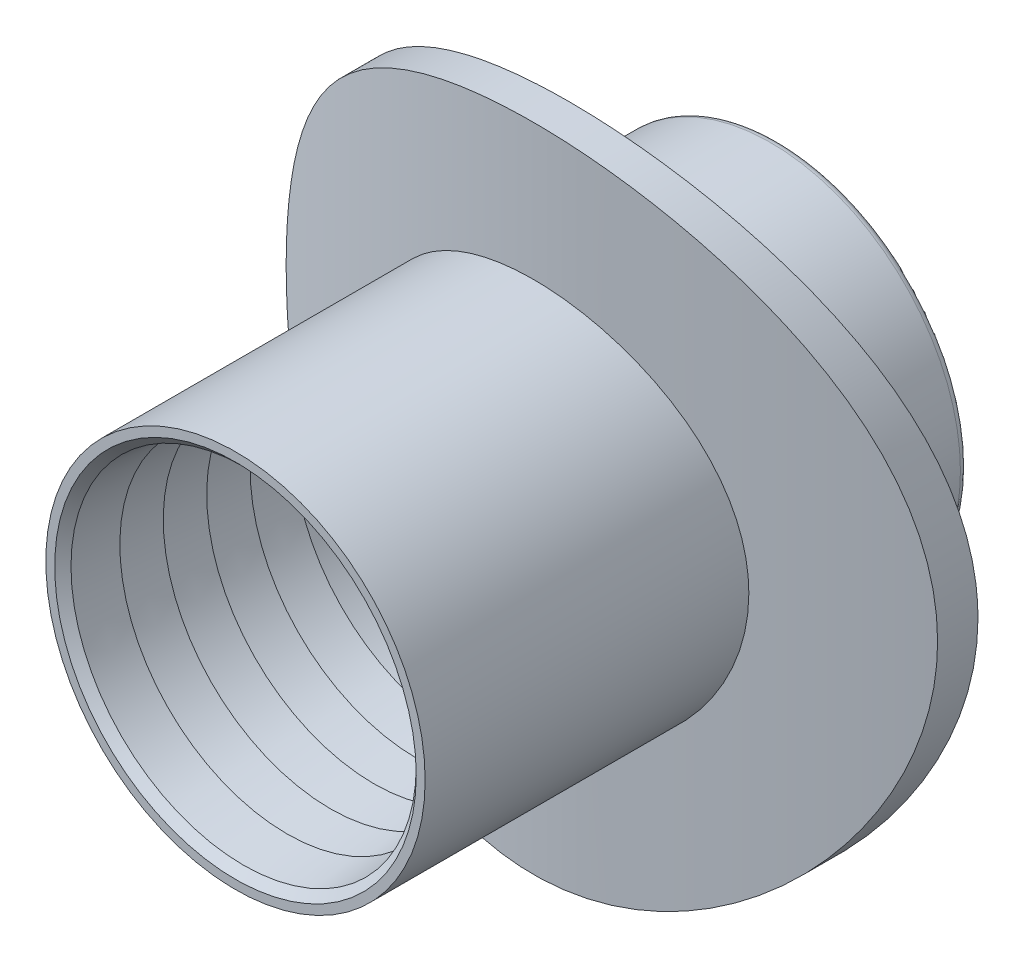
from build123d import *

# Parameters (mm, degrees)
SKETCH2_R                = 30
BOSS_EXTRUDE4_DEPTH      = 2.54
BOSS_EXTRUDE4_DEPTH_BACK = 12.7
SKETCH1_R                = 62.75
CUT_EXTRUDE5_DEPTH       = 31
CUT_EXTRUDE5_DEPTH_BACK  = 31
CUT_EXTRUDE6_DEPTH       = 31.0000001
CUT_EXTRUDE6_DEPTH_BACK  = 31.0000001
SKETCH12_R               = 17.47
BOSS_EXTRUDE7_DEPTH      = 30
BOSS_EXTRUDE7_DEPTH_BACK = 20
SKETCH20_R               = 15.9
CUT_EXTRUDE8_DEPTH       = 51.0000001
CHAMFER1_SIZE            = 0.75
FILLET1_R                = 0.7
LPATTERN1_COUNT          = 5
LPATTERN1_PITCH          = 4


with BuildPart() as part:
    # Sketch2 → Boss-Extrude4 (new body, two sides)
    with BuildSketch(Plane.XY.offset(63.5)) as boss_extrude4_sk:
        Circle(SKETCH2_R)
    extrude(amount=BOSS_EXTRUDE4_DEPTH)
    extrude(boss_extrude4_sk.sketch, amount=-BOSS_EXTRUDE4_DEPTH_BACK)

    # Sketch1 → Cut-Extrude5 (cut, two sides)
    with BuildSketch(Plane(origin=(0, 0, 0), x_dir=(1, 0, 0), z_dir=(0, 1, 0))) as cut_extrude5_sk:
        Circle(SKETCH1_R)
    extrude(amount=CUT_EXTRUDE5_DEPTH, mode=Mode.SUBTRACT)
    extrude(cut_extrude5_sk.sketch, amount=-CUT_EXTRUDE5_DEPTH_BACK, mode=Mode.SUBTRACT)

    # Sketch11 → Cut-Extrude6 (cut, two sides)
    with BuildSketch(Plane(origin=(0, 0, 0), x_dir=(1, 0, 0), z_dir=(0, 1, 0))) as cut_extrude6_sk:
        with BuildLine():
            Line((31.285011062, -58.15951928), (31.285011062, -70.975470201))
            Line((31.285011062, -70.975470201), (-30.859364653, -70.975470201))
            Line((-30.859364653, -70.975470201), (-30.859364653, -58.386481425))
            ThreePointArc((-30.859364653, -58.386481425), (0.241188039, -66.039559571), (31.285011062, -58.15951928))
        make_face()
    extrude(amount=CUT_EXTRUDE6_DEPTH, mode=Mode.SUBTRACT)
    extrude(cut_extrude6_sk.sketch, amount=-CUT_EXTRUDE6_DEPTH_BACK, mode=Mode.SUBTRACT)

    # Sketch12 → Boss-Extrude7 (add, two sides)
    with BuildSketch(Plane.XY.offset(63.5)) as boss_extrude7_sk:
        Circle(SKETCH12_R)
    extrude(amount=BOSS_EXTRUDE7_DEPTH)
    extrude(boss_extrude7_sk.sketch, amount=-BOSS_EXTRUDE7_DEPTH_BACK)

    # Sketch20 → Cut-Extrude8 (cut, through all)
    with BuildSketch(Plane.XY.offset(93.5)):
        Circle(SKETCH20_R)
    extrude(amount=-CUT_EXTRUDE8_DEPTH, mode=Mode.SUBTRACT)

    # Chamfer1
    chamfer1_edges = [part.edges().sort_by_distance(p)[0] for p in [
        (-15.9, 0, 93.5),
    ]]
    chamfer(chamfer1_edges, length=CHAMFER1_SIZE)

    # Fillet1
    fillet1_edges = [part.edges().sort_by_distance(p)[0] for p in [
        (-17.47, 0, 43.5),
        (-15.9, 0, 43.5),
    ]]
    fillet(fillet1_edges, radius=FILLET1_R)

    # Sketch23 → Revolve1 (revolve)
    with BuildSketch(Plane(origin=(0, 0, 0), x_dir=(0, 0, -1), z_dir=(1, 0, 0))):
        Polygon((-92.75, 15.9), (-88.75, 15.9), (-88.75, 15.4), align=None)
    revolve1 = revolve(axis=Axis((0, 0, 93.5), (0, 0, -1)))

    # LPattern1: Revolve1 ×5
    with Locations(*[(0, 0, -i * LPATTERN1_PITCH) for i in range(1, LPATTERN1_COUNT)]):
        add(revolve1)


solid = part.part
